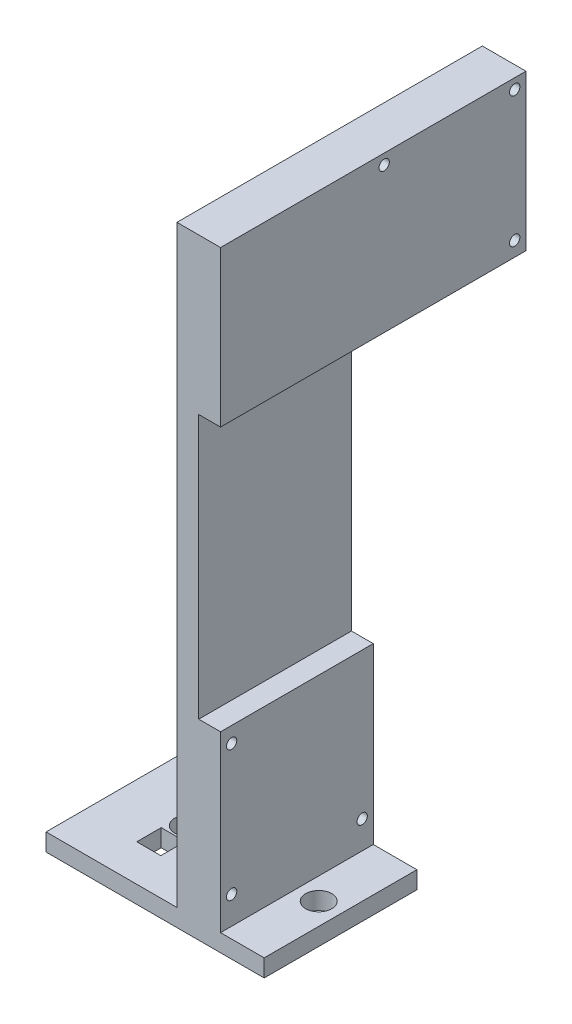
from build123d import *

# Parameters (mm, degrees)
SKETCH1_W                      = 12.7
SKETCH1_H                      = 44.45
HEIGHT_EXTRUDE_DEPTH           = 172.72
SKETCH2_R                      = 1.5
BOTTOM_FAN_MOUNT_CUTS_DEPTH    = 13.7
SKETCH3_W                      = 63.5
SKETCH3_H                      = 44.45
MOUNTING_BASE_EXTRUDE_DEPTH    = 5.08
SKETCH4_R                      = 3.81
MOUNTING_BOLT_HOLE_CUT_DEPTH   = 5.08
SKETCH6_W                      = 6.998886625
SKETCH6_H                      = 7.121323501
OPTIONAL_WIRE_ESCAPE_CUT_DEPTH = 5.08
SKETCH7_W                      = 12.7
SKETCH7_H                      = 45.266682412
BOSS_EXTRUDE1_DEPTH            = 44.45
SKETCH5_R                      = 1.5
TOP_FAN_MOUNT_CUTS_DEPTH       = 51.8
SKETCH8_W                      = 44.45
SKETCH8_H                      = 76.812549829
FILAMENT_NO_STICK_CUT_DEPTH    = 6.35


with BuildPart() as part:
    # Sketch1 → Height extrude (new body)
    with BuildSketch(Plane(origin=(0, 0, 0), x_dir=(1, 0, 0), z_dir=(0, 1, 0))):
        Rectangle(SKETCH1_W, SKETCH1_H)
    extrude(amount=HEIGHT_EXTRUDE_DEPTH)

    # Sketch2 → Bottom Fan Mount Cuts (cut, through all)
    with BuildSketch(Plane(origin=(6.35, 0, 0), x_dir=(0, 0, -1), z_dir=(1, 0, 0))):
        with Locations((-19.0000001, 8.079994)):
            Circle(SKETCH2_R)
        with Locations((19, 8.079994)):
            Circle(SKETCH2_R)
        with Locations((-19.0000001, 46.079994)):
            Circle(SKETCH2_R)
    extrude(amount=-BOTTOM_FAN_MOUNT_CUTS_DEPTH, mode=Mode.SUBTRACT)

    # Sketch3 → Mounting Base Extrude (add)
    with BuildSketch(Plane.XZ):
        with Locations((-12.7, 0)):
            Rectangle(SKETCH3_W, SKETCH3_H)
    extrude(amount=MOUNTING_BASE_EXTRUDE_DEPTH)

    # Sketch4 → Mounting Bolt Hole Cut (cut)
    with BuildSketch(Plane(origin=(0, 0, 0), x_dir=(1, 0, 0), z_dir=(0, 1, 0))):
        with Locations((12.7, 0)):
            Circle(SKETCH4_R)
        with Locations((-25.4, 0)):
            Circle(SKETCH4_R)
    extrude(amount=-MOUNTING_BOLT_HOLE_CUT_DEPTH, mode=Mode.SUBTRACT)

    # Sketch6 → Optional Wire Escape Cut (cut)
    with BuildSketch(Plane(origin=(0, 0, 0), x_dir=(1, 0, 0), z_dir=(0, 1, 0))):
        with Locations((-25.259836811, -7.950336846)):
            Rectangle(SKETCH6_W, SKETCH6_H)
    extrude(amount=-OPTIONAL_WIRE_ESCAPE_CUT_DEPTH, mode=Mode.SUBTRACT)

    # Sketch7 → Boss-Extrude1 (add)
    with BuildSketch(Plane(origin=(0, 0, -22.225), x_dir=(-1, 0, 0), z_dir=(0, 0, -1))):
        with Locations((0, 150.086658794)):
            Rectangle(SKETCH7_W, SKETCH7_H)
    extrude(amount=BOSS_EXTRUDE1_DEPTH)

    # Sketch5 → Top Fan Mount Cuts (cut, through all)
    with BuildSketch(Plane(origin=(6.35, 0, 0), x_dir=(0, 0, -1), z_dir=(1, 0, 0))):
        with Locations((25.4, 169.72)):
            Circle(SKETCH5_R)
        with Locations((63.4, 169.72)):
            Circle(SKETCH5_R)
        with Locations((63.4, 131.72)):
            Circle(SKETCH5_R)
    extrude(amount=-TOP_FAN_MOUNT_CUTS_DEPTH, mode=Mode.SUBTRACT)

    # Sketch8 → Filament no stick cut (cut)
    with BuildSketch(Plane(origin=(6.35, 0, 0), x_dir=(0, 0, -1), z_dir=(1, 0, 0))):
        with Locations((0, 89.047042674)):
            Rectangle(SKETCH8_W, SKETCH8_H)
    extrude(amount=-FILAMENT_NO_STICK_CUT_DEPTH, mode=Mode.SUBTRACT)


solid = part.part
